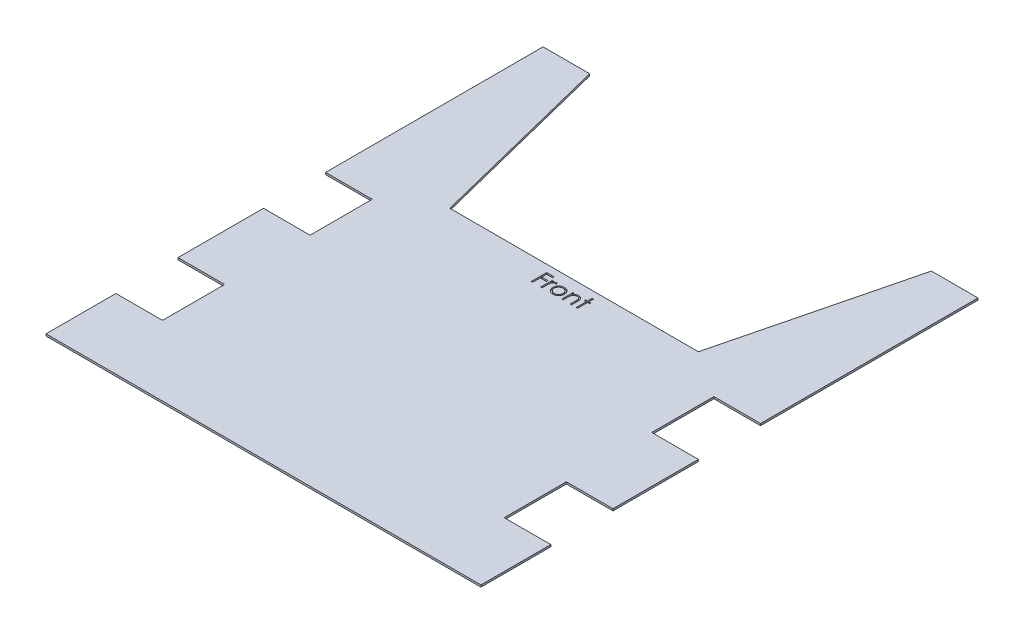
from build123d import *

# Parameters (mm, degrees)
BOSS_EXTRUDE1_DEPTH = 3.175
CUT_EXTRUDE1_DEPTH  = 2.54


with BuildPart() as part:
    # Sketch1 → Boss-Extrude1 (new body)
    with BuildSketch(Plane(origin=(0, 0, 0), x_dir=(1, 0, 0), z_dir=(0, 1, 0))):
        Polygon((-355.6, 203.2), (-279.4, 203.2), (-279.4, 101.6), (-355.6, 101.6), (-355.6, -38.1), (-279.4, -38.1), (-279.4, -139.7), (-355.6, -139.7), (-355.6, -254), (355.6, -254), (355.6, -139.7), (279.4, -139.7), (279.4, -38.1), (355.6, -38.1), (355.6, 101.6), (279.4, 101.6), (279.4, 203.2), (355.6, 203.2), (355.6, 254), (355.6, 558.8), (279.4, 558.8), (203.2, 254), (-203.2, 254), (-279.4, 558.8), (-355.6, 558.8), (-355.6, 254), align=None)
    extrude(amount=BOSS_EXTRUDE1_DEPTH)

    # Sketch3 → Cut-Extrude1 (cut)
    with BuildSketch(Plane(origin=(0, 3.175, 0), x_dir=(1, 0, 0), z_dir=(0, 1, 0))):
        Polygon((-32.986222619, 242.174474666), (-20.611863644, 242.174474666), (-20.611863644, 239.569346461), (-30.706735439, 239.569346461), (-30.706735439, 231.753961845), (-20.611863644, 231.753961845), (-20.611863644, 229.14883364), (-30.706735439, 229.14883364), (-30.706735439, 216.774474666), (-32.986222619, 216.774474666), align=None)
        with BuildLine():
            Line((-17.355453388, 235.336013127), (-15.075966208, 235.336013127))
            Line((-15.075966208, 235.336013127), (-15.075966208, 232.603681396))
            add(Edge.make_bspline(
                [(-15.075966208, 232.603681396), (-14.907682073, 232.858086551), (-14.585839973, 233.344634431), (-14.050894714, 233.988120216), (-13.502956253, 234.520903697), (-12.939401465, 234.94547209), (-12.356086111, 235.263430152), (-11.765812233, 235.496333892), (-11.159293109, 235.63405498), (-10.751718002, 235.652442105), (-10.547520696, 235.661654153)],
                knots=[0, 0, 0, 0, 0.000914564, 0.001749097, 0.002504784, 0.00320288, 0.003858698, 0.004491778, 0.005101612, 0.005713904, 0.005713904, 0.005713904, 0.005713904], degree=3))
            add(Edge.make_bspline(
                [(-10.547520696, 235.661654153), (-10.389123926, 235.653014331), (-10.063212279, 235.635237337), (-9.569852913, 235.510335924), (-9.061537577, 235.310923989), (-8.733932823, 235.123397801), (-8.563145696, 235.025636525)],
                knots=[0, 0, 0, 0, 0.000474945, 0.000977229, 0.001518633, 0.002108264, 0.002108264, 0.002108264, 0.002108264], degree=3))
            Line((-8.563145696, 235.025636525), (-9.814828388, 233.051437807))
            add(Edge.make_bspline(
                [(-9.814828388, 233.051437807), (-9.924476713, 233.100352881), (-10.132610224, 233.193203056), (-10.437080505, 233.303090786), (-10.717796491, 233.367794861), (-10.896638315, 233.377597211), (-10.980012683, 233.382166973)],
                knots=[0, 0, 0, 0, 0.00036011, 0.000683557, 0.000969988, 0.001220136, 0.001220136, 0.001220136, 0.001220136], degree=3))
            add(Edge.make_bspline(
                [(-10.980012683, 233.382166973), (-11.162934292, 233.369974702), (-11.53604135, 233.345106003), (-12.083843146, 233.149607227), (-12.61540858, 232.833738341), (-13.037568644, 232.483427987), (-13.364446708, 232.145623971), (-13.597692916, 231.850632707), (-13.811653422, 231.519862066), (-14.016088736, 231.158966647), (-14.2023527, 230.761784336), (-14.376195156, 230.332283301), (-14.533376619, 229.869966081), (-14.623004105, 229.547875791), (-14.668914926, 229.382888127)],
                knots=[0, 0, 0, 0, 0.000547844, 0.001117443, 0.001723957, 0.002396286, 0.002756143, 0.003132803, 0.003522304, 0.003936948, 0.004376211, 0.004837299, 0.005326449, 0.00584015, 0.00584015, 0.00584015, 0.00584015], degree=3))
            add(Edge.make_bspline(
                [(-14.668914926, 229.382888127), (-14.703258581, 229.235733782), (-14.779327166, 228.909798089), (-14.853288613, 228.362983081), (-14.926364543, 227.716925672), (-14.977865716, 226.96982754), (-15.025603508, 226.123554376), (-15.052528104, 225.176816942), (-15.075048039, 224.128643479), (-15.075650867, 223.395858173), (-15.075966208, 223.012535563)],
                knots=[0, 0, 0, 0, 0.000453102, 0.001003586, 0.001653694, 0.002403742, 0.003249614, 0.004196501, 0.005244855, 0.006394786, 0.006394786, 0.006394786, 0.006394786], degree=3))
            Line((-15.075966208, 223.012535563), (-15.075966208, 216.774474666))
            Line((-15.075966208, 216.774474666), (-17.355453388, 216.774474666))
            Line((-17.355453388, 216.774474666), (-17.355453388, 235.336013127))
        make_face()
        with BuildLine():
            add(Edge.make_bspline(
                [(2.681645971, 235.661654153), (3.029925494, 235.654238143), (3.712816523, 235.63969716), (4.712908038, 235.484285695), (5.667549882, 235.246633393), (6.580398248, 234.9180912), (7.43976222, 234.477713616), (8.258159249, 233.952229046), (9.033345542, 233.32969251), (9.497969811, 232.848122528), (9.733809433, 232.603681396)],
                knots=[0, 0, 0, 0, 0.001044074, 0.002047173, 0.003028248, 0.003992434, 0.004950424, 0.00591863, 0.006906371, 0.007924572, 0.007924572, 0.007924572, 0.007924572], degree=3))
            add(Edge.make_bspline(
                [(9.733809433, 232.603681396), (9.936878471, 232.3698999), (10.339086602, 231.906861222), (10.854820675, 231.156069059), (11.299114283, 230.378538043), (11.6551712, 229.563943158), (11.935913943, 228.719395545), (12.135236425, 227.841992378), (12.253795895, 226.933671345), (12.269783141, 226.316786348), (12.277879946, 226.004362486)],
                knots=[0, 0, 0, 0, 0.000928345, 0.001838724, 0.00272733, 0.003611277, 0.004501061, 0.005393475, 0.006306694, 0.007243796, 0.007243796, 0.007243796, 0.007243796], degree=3))
            add(Edge.make_bspline(
                [(12.277879946, 226.004362486), (12.27075824, 225.690127782), (12.256685419, 225.069185352), (12.123563174, 224.154644811), (11.916509008, 223.267859527), (11.620186525, 222.412542149), (11.240216247, 221.586078202), (10.7765524, 220.792077472), (10.225941236, 220.02897342), (9.601797945, 219.303245793), (8.911992901, 218.634382406), (8.163664282, 218.051428678), (7.371517865, 217.551981044), (6.525020387, 217.149671057), (5.631902054, 216.832463517), (4.690236474, 216.609669112), (3.701486535, 216.474964322), (3.0263747, 216.45766639), (2.681645971, 216.44883364)],
                knots=[0, 0, 0, 0, 0.000942186, 0.001861803, 0.002766434, 0.00367075, 0.004572328, 0.005491255, 0.00642462, 0.007391528, 0.008359519, 0.009302021, 0.010232386, 0.011163196, 0.012107851, 0.013070465, 0.014061347, 0.015095254, 0.015095254, 0.015095254, 0.015095254], degree=3))
            add(Edge.make_bspline(
                [(2.681645971, 216.44883364), (2.335228292, 216.457696035), (1.656751768, 216.475053485), (0.664511784, 216.609145765), (-0.27884145, 216.832360838), (-1.173128994, 217.1507135), (-2.023265883, 217.551993903), (-2.820002175, 218.049918736), (-3.568938705, 218.634555291), (-4.258889677, 219.303198949), (-4.882993842, 220.028985489), (-5.433615102, 220.79207434), (-5.897276327, 221.586079018), (-6.277247292, 222.412541931), (-6.573569591, 223.267859585), (-6.780623807, 224.154644795), (-6.913746038, 225.069185356), (-6.927818861, 225.690127783), (-6.934940567, 226.004362486)],
                knots=[0, 0, 0, 0, 0.00103899, 0.002034915, 0.002997529, 0.003942185, 0.004877587, 0.005812268, 0.00675477, 0.007722761, 0.008689669, 0.009623034, 0.010541962, 0.011443539, 0.012347855, 0.013252486, 0.014172103, 0.015114289, 0.015114289, 0.015114289, 0.015114289], degree=3))
            add(Edge.make_bspline(
                [(-6.934940567, 226.004362486), (-6.926788544, 226.315088276), (-6.910648938, 226.93027194), (-6.792208672, 227.836885465), (-6.593663719, 228.71280366), (-6.312584442, 229.5540914), (-5.953245628, 230.365116565), (-5.515195138, 231.144568767), (-4.994200262, 231.891965947), (-4.593591814, 232.354406185), (-4.390870054, 232.588416973)],
                knots=[0, 0, 0, 0, 0.000932019, 0.001845238, 0.002737652, 0.003622608, 0.0045019, 0.005394938, 0.006301141, 0.007229486, 0.007229486, 0.007229486, 0.007229486], degree=3))
            add(Edge.make_bspline(
                [(-4.390870054, 232.588416973), (-4.155385994, 232.834977961), (-3.692265153, 233.319883528), (-2.913220101, 233.940605274), (-2.09683637, 234.477024782), (-1.227975478, 234.908652174), (-0.315877023, 235.248565988), (0.643656909, 235.484898584), (1.647142078, 235.639137217), (2.333374757, 235.654073707), (2.681645971, 235.661654153)],
                knots=[0, 0, 0, 0, 0.001021792, 0.002009534, 0.002980502, 0.003947584, 0.004913527, 0.005894602, 0.006907768, 0.007951842, 0.007951842, 0.007951842, 0.007951842], degree=3))
        make_face()
        with BuildLine():
            add(Edge.make_bspline(
                [(2.671469689, 233.382166973), (2.425179596, 233.375166794), (1.938957347, 233.361347143), (1.223260933, 233.256235378), (0.534266673, 233.089702062), (-0.129332596, 232.853089768), (-0.765299047, 232.547572045), (-1.374241568, 232.172317088), (-1.957951274, 231.732295061), (-2.505009677, 231.22819453), (-3.0070756, 230.677529827), (-3.445972915, 230.090801736), (-3.819172259, 229.477527109), (-4.130069412, 228.837068205), (-4.361624434, 228.162934687), (-4.529794369, 227.462760964), (-4.634806971, 226.735120513), (-4.64849669, 226.240466265), (-4.655453388, 225.989098063)],
                knots=[0, 0, 0, 0, 0.00073864, 0.001458211, 0.002165335, 0.002862187, 0.00356768, 0.004278018, 0.005004607, 0.005757257, 0.006506476, 0.007237133, 0.007951813, 0.008657306, 0.009368554, 0.010085567, 0.010815214, 0.011569101, 0.011569101, 0.011569101, 0.011569101], degree=3))
            add(Edge.make_bspline(
                [(-4.655453388, 225.989098063), (-4.643792439, 225.664326209), (-4.620647637, 225.019714809), (-4.432431921, 224.070399805), (-4.11757149, 223.159034363), (-3.692395231, 222.290961162), (-3.159675816, 221.48779663), (-2.532026817, 220.771723572), (-1.81618442, 220.153517969), (-1.020681819, 219.640576975), (-0.161767626, 219.233017606), (0.74723539, 218.944190753), (1.695313569, 218.756436185), (2.34323659, 218.737774629), (2.671469689, 218.72832082)],
                knots=[0, 0, 0, 0, 0.000973751, 0.001932714, 0.002890109, 0.00385949, 0.00482475, 0.005772961, 0.006707311, 0.007652898, 0.008604271, 0.009550419, 0.010508423, 0.011492028, 0.011492028, 0.011492028, 0.011492028], degree=3))
            add(Edge.make_bspline(
                [(2.671469689, 218.72832082), (2.999683909, 218.737829711), (3.647569663, 218.756599997), (4.594330546, 218.943245146), (5.500849085, 219.234283141), (6.358871154, 219.640118607), (7.154011648, 220.155465846), (7.875002414, 220.768232697), (8.497292335, 221.489693218), (9.029484782, 222.292024998), (9.461624, 223.157688582), (9.775010665, 224.07056801), (9.96367886, 225.019671971), (9.986762588, 225.664311857), (9.998392766, 225.989098063)],
                knots=[0, 0, 0, 0, 0.000983605, 0.001941609, 0.002882915, 0.003834288, 0.004779875, 0.005718082, 0.006662943, 0.007628203, 0.008599838, 0.009557233, 0.010516196, 0.011489947, 0.011489947, 0.011489947, 0.011489947], degree=3))
            add(Edge.make_bspline(
                [(9.998392766, 225.989098063), (9.991438464, 226.240467768), (9.977753458, 226.735124971), (9.872706574, 227.46274392), (9.704663514, 228.162997221), (9.472640921, 228.836837474), (9.163094649, 229.479185362), (8.782698493, 230.089001096), (8.345593337, 230.679562316), (7.837469089, 231.226414452), (7.290981718, 231.732491574), (6.70703544, 232.172487714), (6.098995882, 232.545922836), (5.464877025, 232.855702982), (4.801192677, 233.087549394), (4.113163796, 233.257196949), (3.400521004, 233.360902947), (2.916041091, 233.375033631), (2.671469689, 233.382166973)],
                knots=[0, 0, 0, 0, 0.000753887, 0.001483534, 0.002200547, 0.002911795, 0.003617288, 0.004334625, 0.005065283, 0.005817932, 0.006570582, 0.007297171, 0.008007509, 0.008708418, 0.009410065, 0.010112247, 0.010831819, 0.011565376, 0.011565376, 0.011565376, 0.011565376], degree=3))
        make_face(mode=Mode.SUBTRACT)
        with BuildLine():
            Line((16.836854304, 235.336013127), (19.116341484, 235.336013127))
            Line((19.116341484, 235.336013127), (19.116341484, 231.988016332))
            add(Edge.make_bspline(
                [(19.116341484, 231.988016332), (19.359728893, 232.29167495), (19.832030652, 232.88093509), (20.618591242, 233.655421546), (21.44985269, 234.293652607), (22.320724373, 234.802405855), (23.232388503, 235.18592137), (24.179287948, 235.462896985), (25.167091815, 235.628975455), (25.838845157, 235.650675983), (26.178681228, 235.661654153)],
                knots=[0, 0, 0, 0, 0.001166783, 0.002264183, 0.003302214, 0.004303182, 0.005281297, 0.006261883, 0.007257301, 0.008276467, 0.008276467, 0.008276467, 0.008276467], degree=3))
            add(Edge.make_bspline(
                [(26.178681228, 235.661654153), (26.522166401, 235.64898902), (27.194449738, 235.624200301), (28.173279098, 235.428136314), (29.087486012, 235.093253605), (29.933810789, 234.63451458), (30.696733994, 234.064056173), (31.366748631, 233.399463128), (31.920927626, 232.635024124), (32.292474203, 231.925833219), (32.537226046, 231.296720255), (32.691312153, 230.757900983), (32.822165561, 230.157603543), (32.93560739, 229.497641954), (33.012367001, 228.77339223), (33.072908203, 227.987823265), (33.116296441, 227.141189518), (33.118017886, 226.555635136), (33.118905587, 226.253681396)],
                knots=[0, 0, 0, 0, 0.001029931, 0.002015823, 0.002980009, 0.003940792, 0.004893294, 0.005828738, 0.006760965, 0.007714567, 0.00822198, 0.008783915, 0.009393749, 0.010064612, 0.010791701, 0.01157765, 0.012428344, 0.01333409, 0.01333409, 0.01333409, 0.01333409], degree=3))
            Line((33.118905587, 226.253681396), (33.118905587, 216.774474666))
            Line((33.118905587, 216.774474666), (30.839418407, 216.774474666))
            Line((30.839418407, 216.774474666), (30.839418407, 225.505724666))
            add(Edge.make_bspline(
                [(30.839418407, 225.505724666), (30.838016269, 225.758436123), (30.835334217, 226.241830133), (30.826874953, 226.933936758), (30.806483785, 227.561582213), (30.777830314, 228.123265965), (30.735891064, 228.618448665), (30.692183968, 229.048138844), (30.638735279, 229.411790952), (30.591107281, 229.630703264), (30.569746933, 229.728881717)],
                knots=[0, 0, 0, 0, 0.00075815, 0.001450212, 0.002076384, 0.002641992, 0.003137218, 0.003567068, 0.003937665, 0.004239027, 0.004239027, 0.004239027, 0.004239027], degree=3))
            add(Edge.make_bspline(
                [(30.569746933, 229.728881717), (30.492635933, 230.017071459), (30.344221115, 230.571747549), (29.97748878, 231.324127136), (29.514380154, 231.964193985), (28.949064333, 232.487990765), (28.287001898, 232.895630551), (27.530030062, 233.178470108), (26.685453641, 233.355372176), (26.091424693, 233.37298622), (25.781806228, 233.382166973)],
                knots=[0, 0, 0, 0, 0.000893327, 0.001719379, 0.002494866, 0.003250964, 0.004016302, 0.004811942, 0.005664141, 0.006591873, 0.006591873, 0.006591873, 0.006591873], degree=3))
            add(Edge.make_bspline(
                [(25.781806228, 233.382166973), (25.598435038, 233.37871254), (25.235548192, 233.371876304), (24.697431253, 233.303286884), (24.175467253, 233.191102664), (23.664417736, 233.03965598), (23.174504033, 232.831649798), (22.689986034, 232.595579511), (22.229108375, 232.301315344), (21.782043721, 231.973360548), (21.366116489, 231.609928588), (20.979105118, 231.226428428), (20.634114914, 230.818028332), (20.321559385, 230.391308713), (20.051751417, 229.940409089), (19.81623472, 229.46967955), (19.61640425, 228.978500527), (19.517106996, 228.637595797), (19.467423215, 228.467022743)],
                knots=[0, 0, 0, 0, 0.000549896, 0.00108823, 0.00162413, 0.002150476, 0.002684343, 0.003219082, 0.003765436, 0.004322093, 0.004881164, 0.005420843, 0.005955073, 0.006483285, 0.007005979, 0.00752934, 0.008061288, 0.00859399, 0.00859399, 0.00859399, 0.00859399], degree=3))
            add(Edge.make_bspline(
                [(19.467423215, 228.467022743), (19.438832622, 228.341799269), (19.376592398, 228.069194318), (19.309368178, 227.62183196), (19.248353203, 227.104325284), (19.197284989, 226.517278183), (19.166039966, 225.858635318), (19.131972058, 225.131209524), (19.119569158, 224.332100208), (19.117447503, 223.775755352), (19.116341484, 223.485732679)],
                knots=[0, 0, 0, 0, 0.000385223, 0.00083861, 0.001356127, 0.001948541, 0.002605876, 0.003334121, 0.004133105, 0.005003192, 0.005003192, 0.005003192, 0.005003192], degree=3))
            Line((19.116341484, 223.485732679), (19.116341484, 216.774474666))
            Line((19.116341484, 216.774474666), (16.836854304, 216.774474666))
            Line((16.836854304, 216.774474666), (16.836854304, 235.336013127))
        make_face()
        Polygon((40.608649176, 242.825756717), (42.888136356, 242.825756717), (42.888136356, 235.336013127), (46.144546612, 235.336013127), (46.144546612, 233.056525948), (42.888136356, 233.056525948), (42.888136356, 216.774474666), (40.608649176, 216.774474666), (40.608649176, 233.056525948), (37.35223892, 233.056525948), (37.35223892, 235.336013127), (40.608649176, 235.336013127), align=None)
    extrude(amount=-CUT_EXTRUDE1_DEPTH, mode=Mode.SUBTRACT)


solid = part.part
